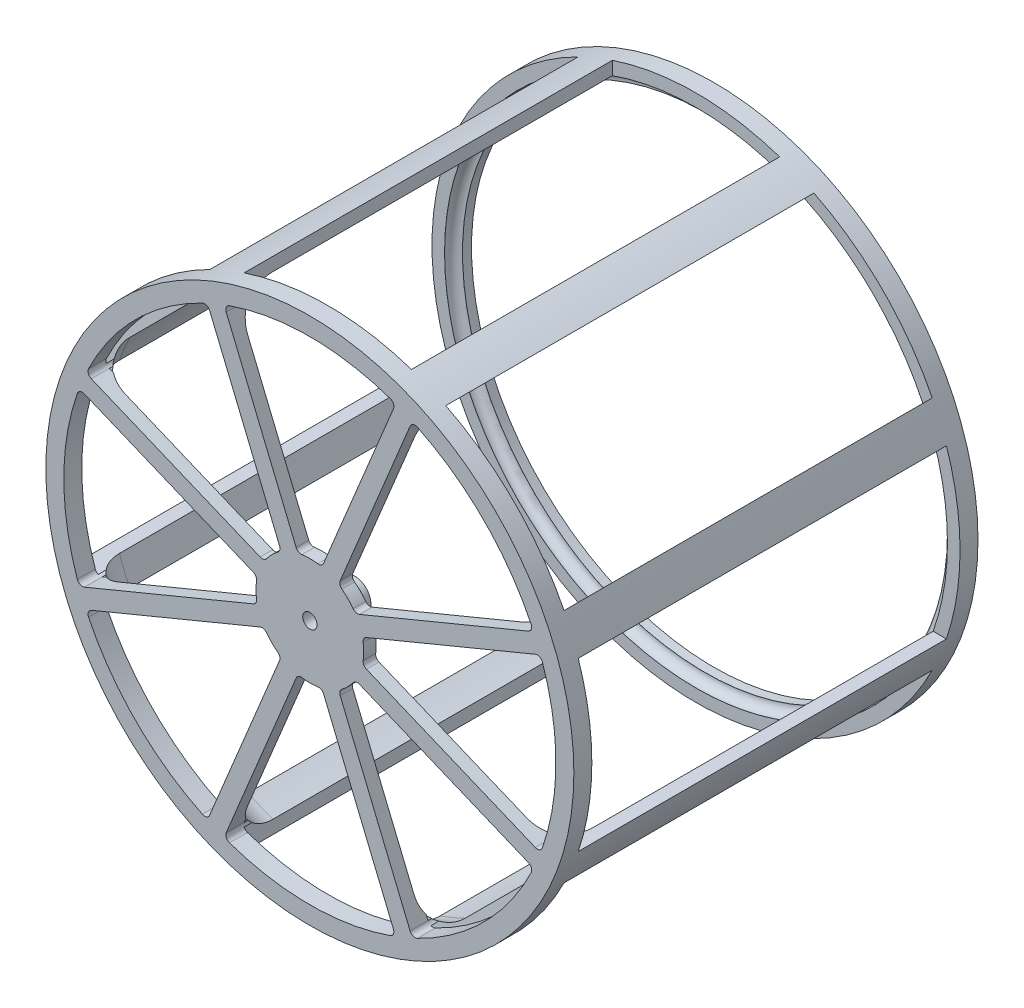
from build123d import *

# Parameters (mm, degrees)
SPOKE_DEPTH       = 7.62
TREAD_START       = 15.24
SKETCH4_W         = 23.656906514
SKETCH4_H         = 52.07
TREAD_DEPTH       = 23.098
CIRPATTERN1_COUNT = 8


with BuildPart() as part:
    # Sketch1 → Revolve1 (revolve)
    with BuildSketch(Plane(origin=(0, 0, 0), x_dir=(0, 0, -1), z_dir=(1, 0, 0))):
        with BuildLine():
            Line((1.778, 6.096), (1.778, 30.734))
            ThreePointArc((1.778, 30.734), (3.191502674, 34.146497326), (6.604, 35.56))
            Line((6.604, 35.56), (54.6354, 35.56))
            ThreePointArc((54.6354, 35.56), (55.5154651, 35.1954651), (55.88, 34.3154))
            Line((55.88, 34.3154), (55.88, 34.29))
            Line((55.88, 34.29), (57.15, 34.29))
            Line((57.15, 34.29), (57.15, 37.338))
            Line((57.15, 37.338), (0, 37.338))
            Line((0, 37.338), (0, 1.016))
            Line((0, 1.016), (6.35, 1.016))
            Line((6.35, 1.016), (6.35, 2.286))
            Line((6.35, 2.286), (5.588, 2.286))
            ThreePointArc((5.588, 2.286), (2.893923164, 3.401923164), (1.778, 6.096))
        make_face()
    revolve(axis=Axis((0, 0, 0), (0, 0, -1)))

    # Sketch3 → Spoke (cut)
    with BuildSketch(Plane.XY):
        with BuildLine():
            Line((1.938642336, 7.998966552), (11.828453257, 31.875082205))
            ThreePointArc((11.828453257, 31.875082205), (11.819430748, 32.47918588), (11.373512061, 32.886836689))
            ThreePointArc((11.373512061, 32.886836689), (0, 34.798), (-11.373512061, 32.886836689))
            ThreePointArc((-11.373512061, 32.886836689), (-11.819430748, 32.47918588), (-11.828453257, 31.875082205))
            Line((-11.828453257, 31.875082205), (-1.938642336, 7.998966552))
            ThreePointArc((-1.938642336, 7.998966552), (-1.610044564, 7.627457447), (-1.122405575, 7.536883025))
            ThreePointArc((-1.122405575, 7.536883025), (0, 7.62), (1.122405575, 7.536883025))
            ThreePointArc((1.122405575, 7.536883025), (1.610044564, 7.627457447), (1.938642336, 7.998966552))
        make_face()
    spoke = extrude(amount=-SPOKE_DEPTH, mode=Mode.SUBTRACT)

    # Sketch4 → Tread (cut, through all)
    with BuildSketch(Plane(origin=(0, 0, 0), x_dir=(1, 0, 0), z_dir=(0, 1, 0)).offset(TREAD_START)):
        with Locations((0, 28.575)):
            Rectangle(SKETCH4_W, SKETCH4_H)
    tread = extrude(amount=TREAD_DEPTH, mode=Mode.SUBTRACT)

    # CirPattern1: Spoke, Tread ×8 about axis
    cirpattern1_axis = Axis((0, 0, 0), (0, 0, 1))
    for i in range(1, CIRPATTERN1_COUNT):
        add(spoke.rotate(cirpattern1_axis, i * 360 / CIRPATTERN1_COUNT), mode=Mode.SUBTRACT)
        add(tread.rotate(cirpattern1_axis, i * 360 / CIRPATTERN1_COUNT), mode=Mode.SUBTRACT)


solid = part.part
